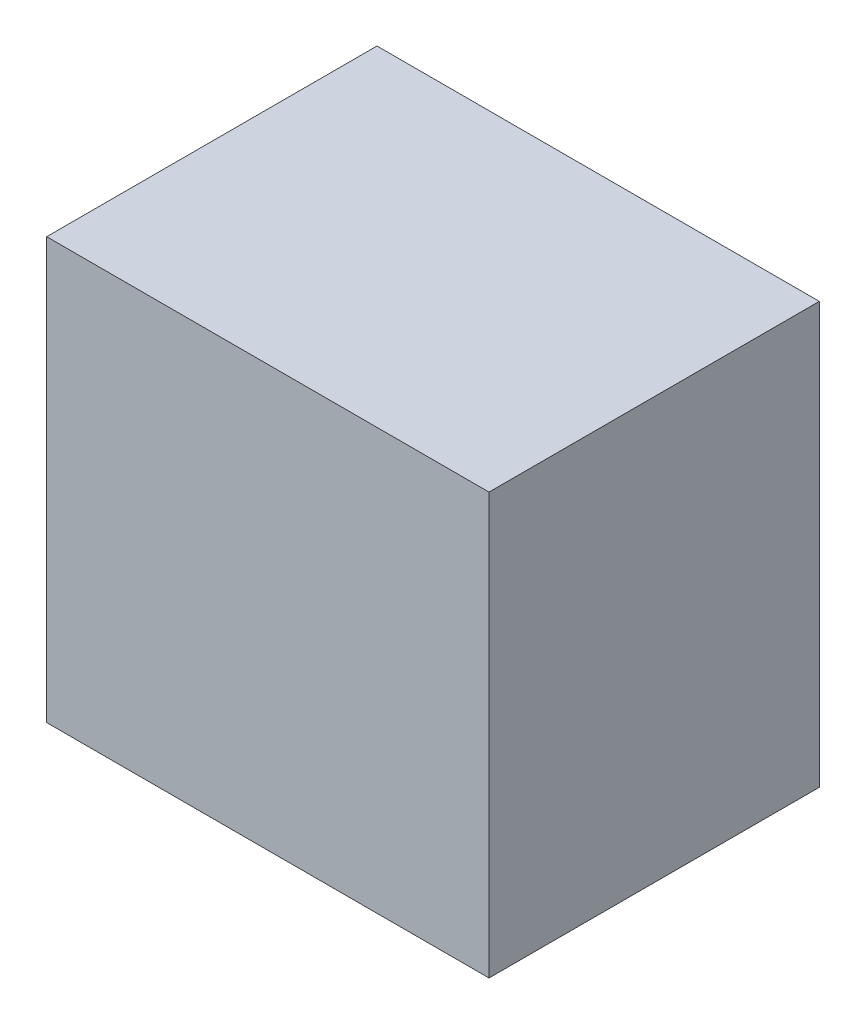
from build123d import *

# Parameters (mm, degrees)
SKETCH1_W           = 235.443759118
SKETCH1_H           = 175.809341662
BOSS_EXTRUDE1_DEPTH = 112


with BuildPart() as part:
    # Sketch1 → Boss-Extrude1 (new body, symmetric)
    with BuildSketch(Plane(origin=(0, 0, 0), x_dir=(1, 0, 0), z_dir=(0, 1, 0))):
        Rectangle(SKETCH1_W, SKETCH1_H)
    extrude(amount=BOSS_EXTRUDE1_DEPTH, both=True)


solid = part.part
